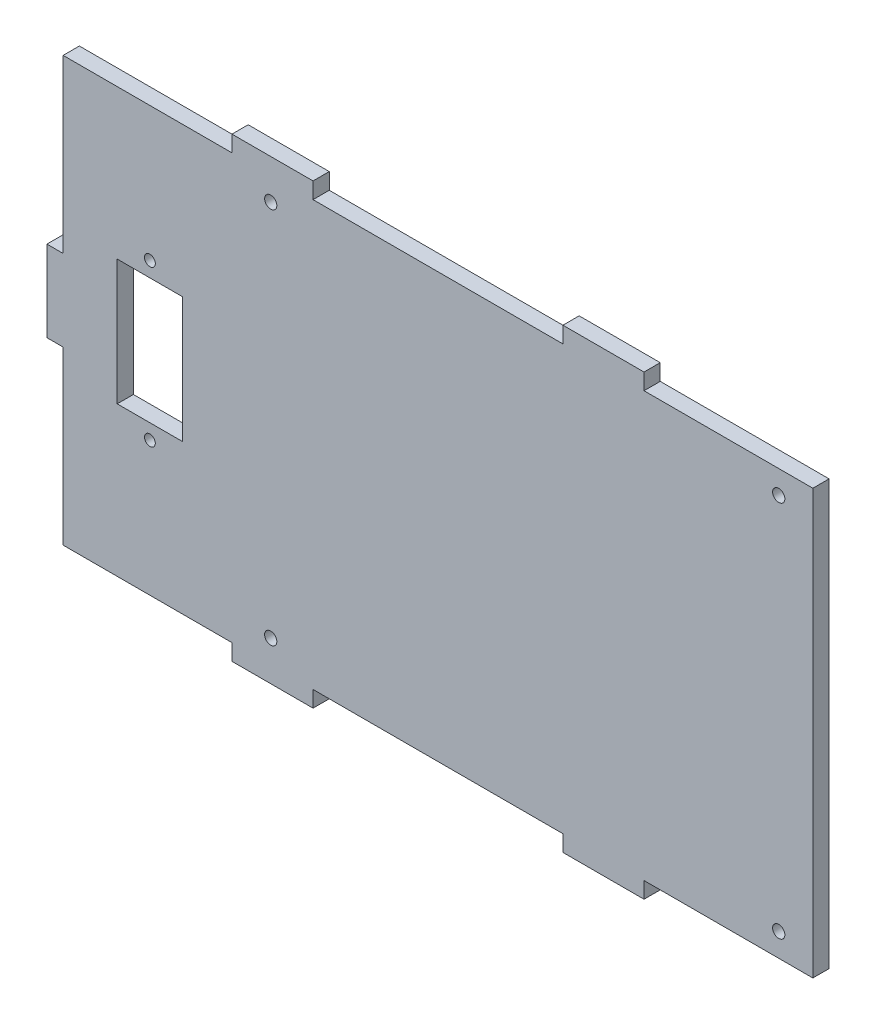
from build123d import *

# Parameters (mm, degrees)
BOSS_EXTRUDE1_DEPTH = 3
SKETCH2_R           = 1.13
CUT_EXTRUDE1_DEPTH  = 3
SKETCH3_R           = 1
SKETCH3_W           = 12.1
SKETCH3_H           = 23.2
CUT_EXTRUDE4_DEPTH  = 3


with BuildPart() as part:
    # Sketch1 → Boss-Extrude1 (new body)
    with BuildSketch(Plane.XY):
        Polygon((-36.547918648, 71.490037876), (-5.317918648, 71.490037876), (-5.317918648, 74.490037876), (9.682081352, 74.490037876), (9.682081352, 71.490037876), (55.912081352, 71.490037876), (55.912081352, 74.490037876), (70.912081352, 74.490037876), (70.912081352, 71.490037876), (102.145081352, 71.490037876), (102.142081352, -6.979962124), (70.912081352, -6.979962124), (70.912081352, -9.979962124), (55.912081352, -9.979962124), (55.912081352, -6.979962124), (9.682081352, -6.979962124), (9.682081352, -9.979962124), (-5.317918648, -9.979962124), (-5.317918648, -6.979962124), (-36.547918648, -6.979962124), (-36.547918648, 24.755037876), (-39.547918648, 24.755037876), (-39.547918648, 39.755037876), (-36.547918648, 39.755037876), align=None)
    extrude(amount=BOSS_EXTRUDE1_DEPTH)

    # Sketch2 → Cut-Extrude1 (cut)
    with BuildSketch(Plane.XY.offset(3)):
        with Locations((95.834916571, 67.180037876)):
            Circle(SKETCH2_R)
        with Locations((95.832246124, -2.669962124)):
            Circle(SKETCH2_R)
        with Locations((1.854916503, 67.180037876)):
            Circle(SKETCH2_R)
        with Locations((1.852246055, -2.669962124)):
            Circle(SKETCH2_R)
    extrude(amount=-CUT_EXTRUDE1_DEPTH, mode=Mode.SUBTRACT)

    # Sketch3 → Cut-Extrude4 (cut)
    with BuildSketch(Plane.XY.offset(3)):
        with Locations((-20.497918648, 46.660037876)):
            Circle(SKETCH3_R)
        with Locations((-20.497918648, 17.860037876)):
            Circle(SKETCH3_R)
        with Locations((-20.497918648, 32.260037876)):
            Rectangle(SKETCH3_W, SKETCH3_H)
    extrude(amount=-CUT_EXTRUDE4_DEPTH, mode=Mode.SUBTRACT)


solid = part.part
